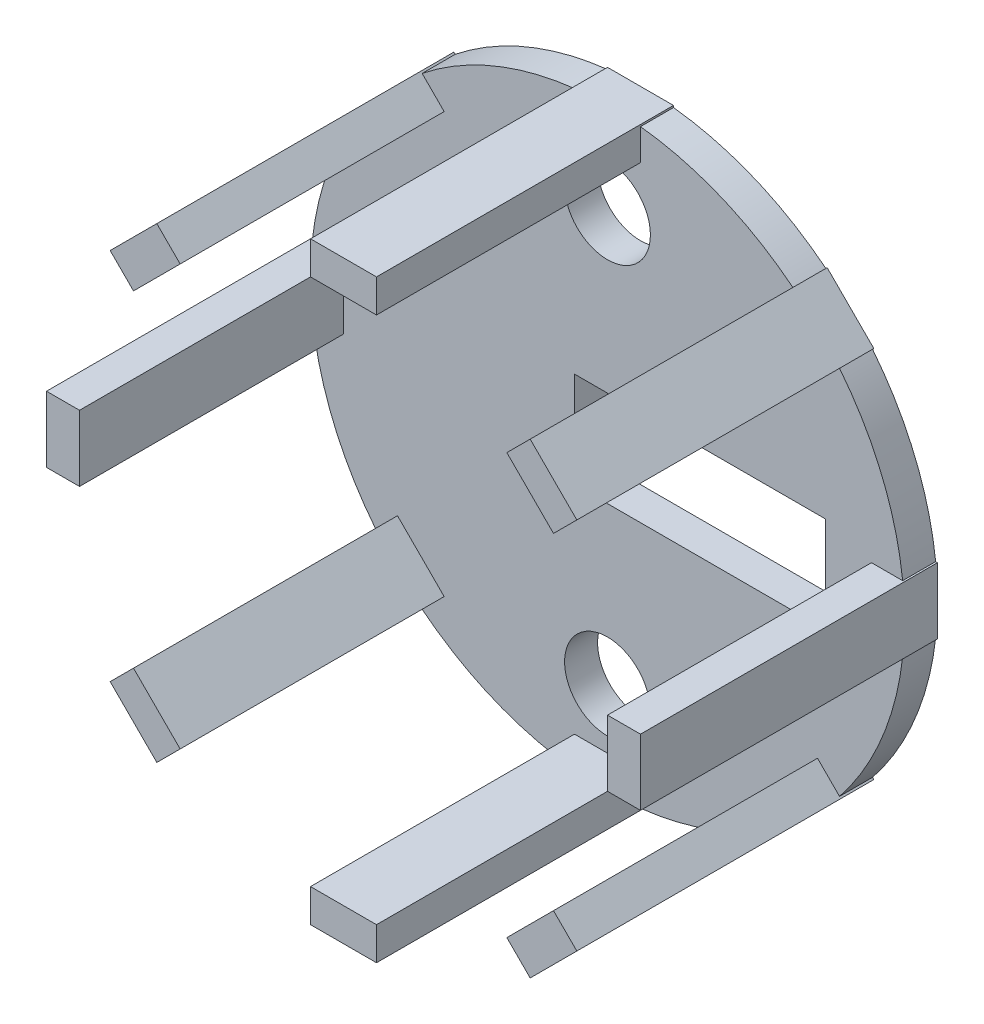
from build123d import *

# Parameters (mm, degrees)
SKETCH_1_R          = 9
EXTRUDE_1_DEPTH     = 1
SKETCH_2_R          = 1.3
CUT_EXTRUDE_1_DEPTH = 13.767145335
SKETCH_4_W          = 7.6
SKETCH_4_H          = 2.9
CUT_EXTRUDE_6_DEPTH = 13.767145335
SKETCH_5_W          = 1
SKETCH_5_H          = 2
SKETCH_5_W_2        = 2
SKETCH_5_H_2        = 1
EXTRUDE_3_DEPTH     = 9


with BuildPart() as part:
    # ｽｹｯﾁ1 → ﾎﾞｽ - 押し出し1 (new body)
    with BuildSketch(Plane.XY):
        Circle(SKETCH_1_R)
    extrude(amount=EXTRUDE_1_DEPTH)

    # ｽｹｯﾁ2 → ｶｯﾄ - 押し出し1 (cut, through all)
    with BuildSketch(Plane.XY):
        with Locations((0, 6.25)):
            Circle(SKETCH_2_R)
        with Locations((0, -6.25)):
            Circle(SKETCH_2_R)
    extrude(amount=CUT_EXTRUDE_1_DEPTH, mode=Mode.SUBTRACT)

    # ｽｹｯﾁ4 → ｶｯﾄ - 押し出し6 (cut, through all)
    with BuildSketch(Plane.XY):
        with Locations((2.8, 0)):
            Rectangle(SKETCH_4_W, SKETCH_4_H)
    extrude(amount=CUT_EXTRUDE_6_DEPTH, mode=Mode.SUBTRACT)

    # ｽｹｯﾁ5 → ﾎﾞｽ - 押し出し3 (add)
    with BuildSketch(Plane.XY):
        Polygon((-6.363961031, 4.949747468), (-4.949747468, 6.363961031), (-5.656854249, 7.071067812), (-7.071067812, 5.656854249), align=None)
        with Locations((-8.5, 0)):
            Rectangle(SKETCH_5_W, SKETCH_5_H)
        with Locations((0, 8.5)):
            Rectangle(SKETCH_5_W_2, SKETCH_5_H_2)
        Polygon((4.949747468, 6.363961031), (6.363961031, 4.949747468), (7.071067812, 5.656854249), (5.656854249, 7.071067812), align=None)
        with Locations((8.5, 0)):
            Rectangle(SKETCH_5_W, SKETCH_5_H)
        Polygon((6.363961031, -4.949747468), (4.949747468, -6.363961031), (5.656854249, -7.071067812), (7.071067812, -5.656854249), align=None)
        with Locations((0, -8.5)):
            Rectangle(SKETCH_5_W_2, SKETCH_5_H_2)
        Polygon((-4.949747468, -6.363961031), (-6.363961031, -4.949747468), (-7.071067812, -5.656854249), (-5.656854249, -7.071067812), align=None)
    extrude(amount=EXTRUDE_3_DEPTH)


solid = part.part
